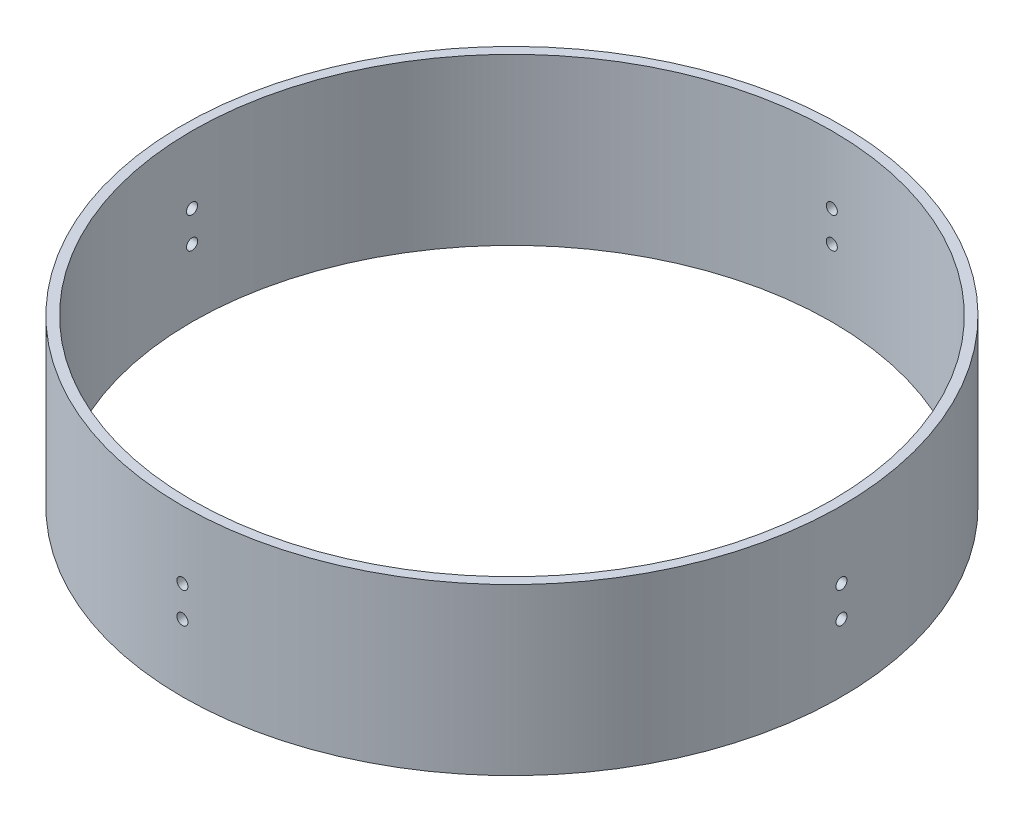
from build123d import *

# Parameters (mm, degrees)
SKETCH1_R               = 75.8825
BOSS_EXTRUDE1_DEPTH     = 38.1
SKETCH2_R               = 73.66
CUT_EXTRUDE1_DEPTH      = 101.6
SKETCH4_R               = 1.27
CUT_EXTRUDE3_DEPTH      = 76.8825
CUT_EXTRUDE3_DEPTH_BACK = 76.8825
SKETCH5_R               = 1.27
CUT_EXTRUDE4_DEPTH      = 76.8825001
CUT_EXTRUDE4_DEPTH_BACK = 76.8825001


with BuildPart() as part:
    # Sketch1 → Boss-Extrude1 (new body)
    with BuildSketch(Plane(origin=(0, 0, 0), x_dir=(1, 0, 0), z_dir=(0, 1, 0))):
        Circle(SKETCH1_R)
    extrude(amount=BOSS_EXTRUDE1_DEPTH)

    # Sketch2 → Cut-Extrude1 (cut)
    with BuildSketch(Plane(origin=(0, 38.1, 0), x_dir=(1, 0, 0), z_dir=(0, 1, 0))):
        Circle(SKETCH2_R)
    extrude(amount=-CUT_EXTRUDE1_DEPTH, mode=Mode.SUBTRACT)

    # Sketch4 → Cut-Extrude3 (cut, two sides)
    with BuildSketch(Plane(origin=(0, 0, 0), x_dir=(0, 0, -1), z_dir=(1, 0, 0))) as cut_extrude3_sk:
        with Locations((4.12e-07, 22.606)):
            Circle(SKETCH4_R)
        with Locations((4.12e-07, 15.494)):
            Circle(SKETCH4_R)
    extrude(amount=CUT_EXTRUDE3_DEPTH, mode=Mode.SUBTRACT)
    extrude(cut_extrude3_sk.sketch, amount=-CUT_EXTRUDE3_DEPTH_BACK, mode=Mode.SUBTRACT)

    # Sketch5 → Cut-Extrude4 (cut, two sides)
    with BuildSketch(Plane.XY) as cut_extrude4_sk:
        with Locations((7.8e-08, 15.493965738)):
            Circle(SKETCH5_R)
        with Locations((6.87e-07, 22.605965738)):
            Circle(SKETCH5_R)
    extrude(amount=CUT_EXTRUDE4_DEPTH, mode=Mode.SUBTRACT)
    extrude(cut_extrude4_sk.sketch, amount=-CUT_EXTRUDE4_DEPTH_BACK, mode=Mode.SUBTRACT)


solid = part.part
